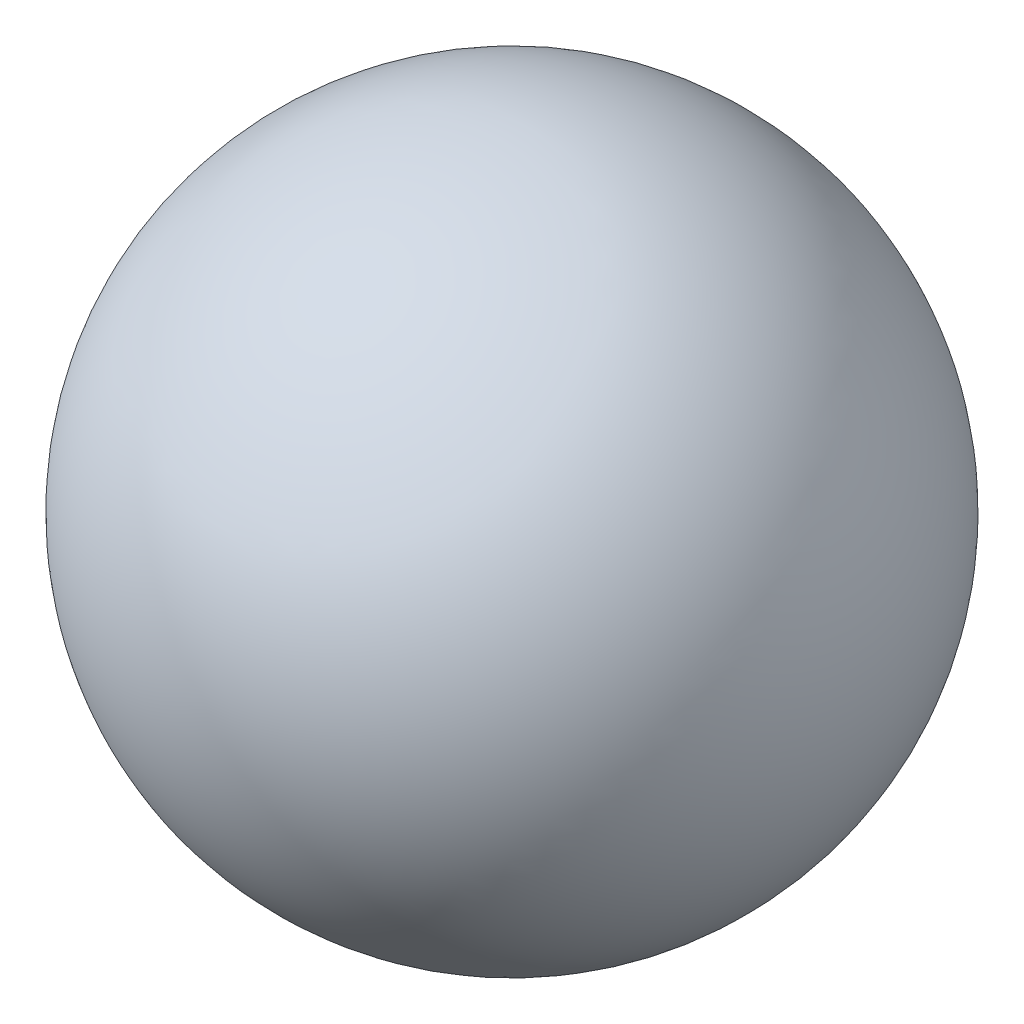
from build123d import *


with BuildPart() as part:
    # Sketch1 one side → Revolve1 (revolve)
    with BuildSketch(Plane(origin=(0, 0, 0), x_dir=(0, 0, -1), z_dir=(1, 0, 0))):
        with BuildLine():
            Line((-20, 0), (20, 0))
            ThreePointArc((20, 0), (0, 20), (-20, 0))
        make_face()
    revolve(axis=Axis((0, 0, 20), (0, 0, -1)))


solid = part.part
